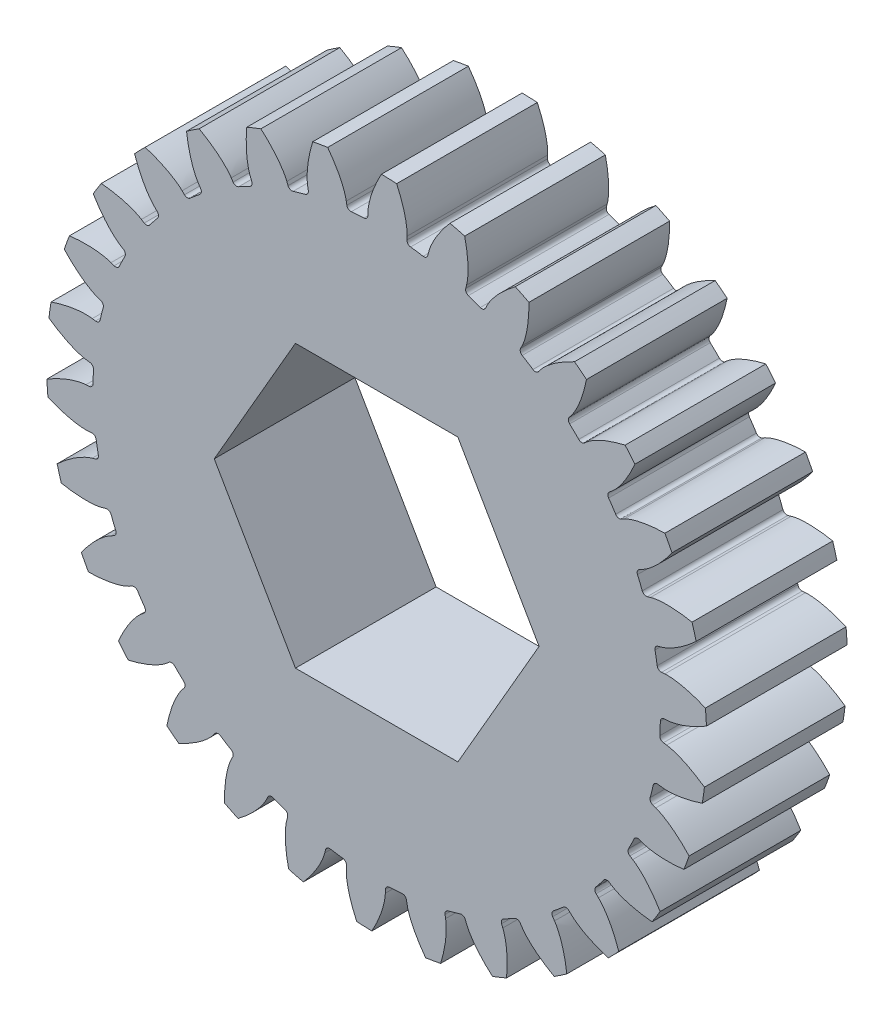
from build123d import *

# Parameters (mm, degrees)
SKETCH1_R                = 30.25
BOSS_EXTRUDE1_DEPTH      = 7.5
BOSS_EXTRUDE2_DEPTH      = 7.5
BOSS_EXTRUDE3_DEPTH      = 7.5
FILLET1_R                = 0.44
CIRPATTERN1_COUNT        = 30
FILLET1_OF_CIRPATTERN1_R = 0.44
CUT_EXTRUDE1_DEPTH       = 52.96538652


with BuildPart() as part:
    # Sketch1 → Boss-Extrude1 (new, symmetric)
    with BuildSketch(Plane.XY):
        Circle(SKETCH1_R)
    extrude(amount=BOSS_EXTRUDE1_DEPTH, both=True)

    # Sketch4 → Boss-Extrude2 (add, symmetric)
    with BuildSketch(Plane.XY):
        with BuildLine():
            Line((30.939730534, 2.084292147), (30.181592394, 2.03321926))
            ThreePointArc((30.181592394, 2.03321926), (30.232893261, 1.01718486), (30.25, 0))
            ThreePointArc((30.25, 0), (30.249989171, -0.025595791), (30.249956685, -0.051191564))
            Line((30.249956685, -0.051191564), (31.009856486, 0))
            ThreePointArc((31.009856486, 0), (30.992320039, 1.042735753), (30.939730534, 2.084292147))
        make_face()
        with BuildLine():
            ThreePointArc((29.969770044, 4.107965859), (30.093566491, 3.072418565), (30.181592394, 2.03321926))
            Line((30.181592394, 2.03321926), (30.939730534, 2.084292147))
            ThreePointArc((30.939730534, 2.084292147), (30.85214745, 3.123491156), (30.729669846, 4.159157422))
            Line((30.729669846, 4.159157422), (29.969770044, 4.107965859))
        make_face()
    boss_extrude2 = extrude(amount=BOSS_EXTRUDE2_DEPTH, both=True)

    # Sketch6 → Boss-Extrude3 (add, symmetric)
    with BuildSketch(Plane.XY):
        with BuildLine():
            ThreePointArc((30.729669846, 4.159157422), (30.939730534, 2.084292147), (31.009856486, 0))
            add(Edge.make_bspline(
                [(31.009856486, 0), (31.057646427, 0.00152442), (31.153029989, 0.00743036), (31.419459867, 0.038932409), (31.921419499, 0.137427154), (32.675495048, 0.3542441), (33.628154104, 0.730605066), (34.38993751, 1.11037961), (34.918887585, 1.409140911), (35.16558954, 1.556056662)],
                knots=[0, 0, 0, 0, 0, 0.002802036, 0.005604071, 0.015718253, 0.029959921, 0.048733673, 0.065569115, 0.065569115, 0.065569115, 0.065569115, 0.065569115], degree=4))
            ThreePointArc((35.16558954, 1.556056662), (35.120398422, 2.365927866), (35.056558278, 3.174542756))
            add(Edge.make_bspline(
                [(30.729669846, 4.159157422), (30.777232446, 4.164056541), (30.872546306, 4.170997162), (31.140794053, 4.175514314), (31.651428758, 4.145234204), (32.427771225, 4.031515707), (33.422301554, 3.786329496), (34.228138713, 3.512159596), (34.792380488, 3.287042479), (35.056558278, 3.174542756)],
                knots=[0, 0, 0, 0, 0, 0.002802036, 0.005604071, 0.015718253, 0.029959921, 0.048733673, 0.065569115, 0.065569115, 0.065569115, 0.065569115, 0.065569115], degree=4))
        make_face()
    boss_extrude3 = extrude(amount=BOSS_EXTRUDE3_DEPTH, both=True)

    # Fillet1
    fillet1_edges = [part.edges().sort_by_distance(p)[0] for p in [
        (29.969770044, 4.107965859, 0),
        (30.249956685, -0.051191564, 0),
    ]]
    fillet(fillet1_edges, radius=FILLET1_R)

    # CirPattern1: Boss-Extrude2, Boss-Extrude3 ×30 about axis
    cirpattern1_axis = Axis((0, 0, 7.5), (0, 0, -1))
    add([boss_extrude2.rotate(cirpattern1_axis, i * 360 / CIRPATTERN1_COUNT) for i in range(1, CIRPATTERN1_COUNT)])
    add([boss_extrude3.rotate(cirpattern1_axis, i * 360 / CIRPATTERN1_COUNT) for i in range(1, CIRPATTERN1_COUNT)])

    # Fillet1 of CirPattern1
    fillet1_of_cirpattern1_edges = [part.edges().sort_by_distance(p)[0] for p in [
        (30.168952791, -2.212868615, 0),
        (29.578279229, -6.339392547, 0),
        (29.049607534, -8.436990111, 0),
        (27.613889038, -12.350531656, 0),
        (26.660655032, -14.292374655, 0),
        (24.442639391, -17.821893267, 0),
        (23.106503973, -19.523113843, 0),
        (20.203129113, -22.514352623, 0),
        (18.542487814, -23.900599275, 0),
        (15.080645148, -26.222826734, 0),
        (13.16807596, -27.23351383, 0),
        (9.299064624, -28.785237486, 0),
        (7.218155999, -29.37619315, 0),
        (3.111070355, -30.089595232, 0),
        (0.952767985, -30.234991867, 0),
        (-3.212892617, -30.078893281, 0),
        (-5.354260563, -29.772376355, 0),
        (-9.396436765, -28.753599359, 0),
        (-11.427282231, -28.008565133, 0),
        (-15.169311537, -26.17163517, 0),
        (-17.000876831, -25.020645215, 0),
        (-20.279214604, -22.445844939, 0),
        (-21.831451535, -20.939203039, 0),
        (-24.502818683, -17.739063577, 0),
        (-25.707887047, -15.942617212, 0),
        (-27.655532008, -12.257000015, 0),
        (-28.460764536, -10.249262512, 0),
        (-29.599565878, -6.239246736, 0),
        (-29.969770044, -4.107965859, 0),
        (-30.249956685, 0.051191564, 0),
        (-30.168952791, 2.212868615, 0),
        (-29.578279229, 6.339392547, 0),
        (-29.049607534, 8.436990111, 0),
        (-27.613889038, 12.350531656, 0),
        (-26.660655032, 14.292374655, 0),
        (-24.442639391, 17.821893267, 0),
        (-23.106503973, 19.523113843, 0),
        (-20.203129113, 22.514352623, 0),
        (-18.542487814, 23.900599275, 0),
        (-15.080645148, 26.222826734, 0),
        (-13.16807596, 27.23351383, 0),
        (-9.299064624, 28.785237486, 0),
        (-7.218155999, 29.37619315, 0),
        (-3.111070355, 30.089595232, 0),
        (-0.952767985, 30.234991867, 0),
        (3.212892617, 30.078893281, 0),
        (5.354260563, 29.772376355, 0),
        (9.396436765, 28.753599359, 0),
        (11.427282231, 28.008565133, 0),
        (15.169311537, 26.17163517, 0),
        (17.000876831, 25.020645215, 0),
        (20.279214604, 22.445844939, 0),
        (21.831451535, 20.939203039, 0),
        (24.502818683, 17.739063577, 0),
        (25.707887047, 15.942617212, 0),
        (27.655532008, 12.257000015, 0),
        (28.460764536, 10.249262512, 0),
        (29.599565878, 6.239246736, 0),
    ]]
    fillet(fillet1_of_cirpattern1_edges, radius=FILLET1_OF_CIRPATTERN1_R)

    # Sketch7 → Cut-Extrude1 (cut, through all)
    with BuildSketch(Plane.XY.offset(7.5)):
        Polygon((8.660254038, 15), (-8.660254038, 15), (-17.320508076, 0), (-8.660254038, -15), (8.660254038, -15), (17.320508076, 0), align=None)
    extrude(amount=-CUT_EXTRUDE1_DEPTH, mode=Mode.SUBTRACT)


solid = part.part
